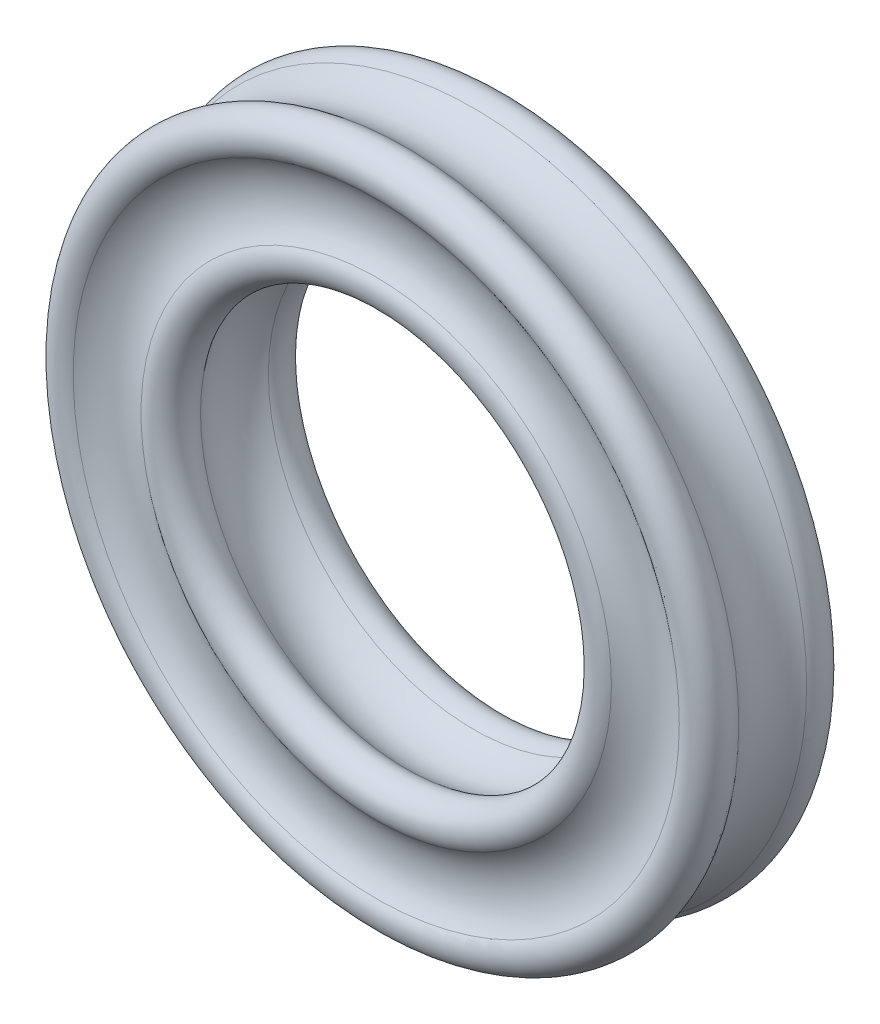
from build123d import *


with BuildPart() as part:
    # Sketch1 → Revolve1 (revolve)
    with BuildSketch(Plane(origin=(0, 0, 0), x_dir=(0, 0, -1), z_dir=(1, 0, 0))):
        with BuildLine():
            ThreePointArc((-0.642857143, 6.306394437), (0, 6.072380529), (0.642857143, 6.306394437))
            ThreePointArc((0.642857143, 6.306394437), (1.182842712, 6.282842712), (1.206394437, 5.742857143))
            ThreePointArc((1.206394437, 5.742857143), (0.972380529, 5.1), (1.206394437, 4.457142857))
            ThreePointArc((1.206394437, 4.457142857), (1.182842712, 3.917157288), (0.642857143, 3.893605563))
            ThreePointArc((0.642857143, 3.893605563), (0, 4.127619471), (-0.642857143, 3.893605563))
            ThreePointArc((-0.642857143, 3.893605563), (-1.182842712, 3.917157288), (-1.206394437, 4.457142857))
            ThreePointArc((-1.206394437, 4.457142857), (-0.972380529, 5.1), (-1.206394437, 5.742857143))
            ThreePointArc((-1.206394437, 5.742857143), (-1.182842712, 6.282842712), (-0.642857143, 6.306394437))
        make_face()
    revolve(axis=Axis((0, 0, 0), (0, 0, -1)))


solid = part.part
